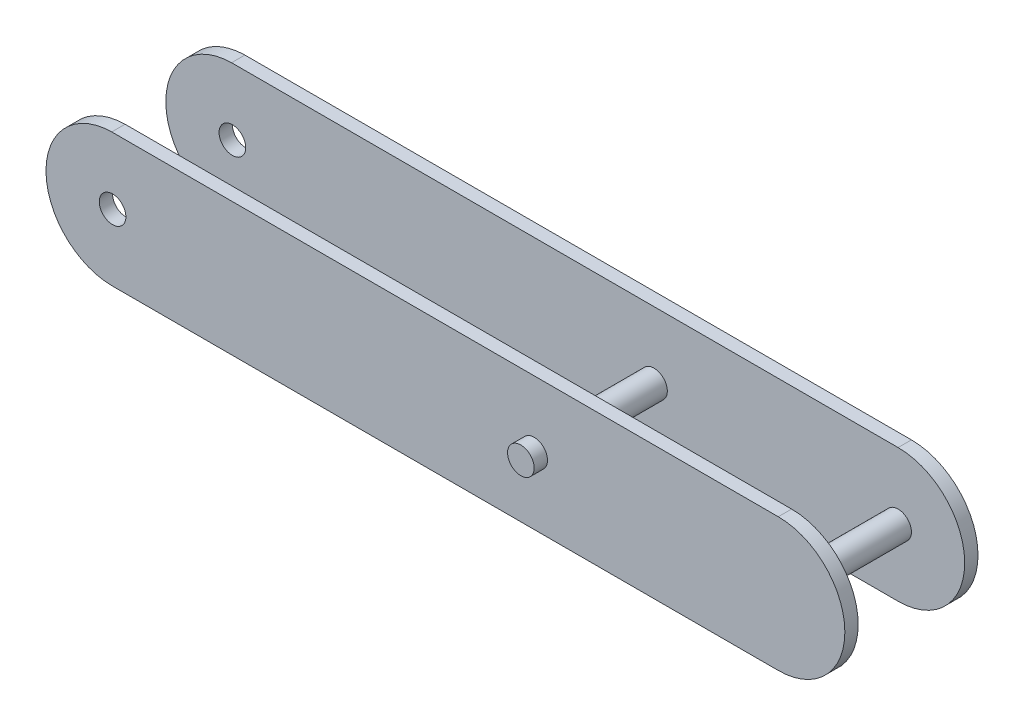
from build123d import *

# Parameters (mm, degrees)
CROQUIS2_R              = 3
SALIENTE_EXTRUIR1_DEPTH = 18
CROQUIS3_R              = 3
SALIENTE_EXTRUIR2_DEPTH = 18
CROQUIS4_W              = 3
CROQUIS4_H              = 30
SALIENTE_EXTRUIR3_DEPTH = 110
CROQUIS5_W              = 3
CROQUIS5_H              = 30
SALIENTE_EXTRUIR4_DEPTH = 70
CORTAR_EXTRUIR1_DEPTH   = 70
CORTAR_EXTRUIR2_DEPTH   = 70
CROQUIS8_R              = 3
CORTAR_EXTRUIR3_DEPTH   = 70
CROQUIS9_R              = 3
SALIENTE_EXTRUIR6_DEPTH = 30


with BuildPart() as part:
    # Croquis2 → Saliente-Extruir1 (new body)
    with BuildSketch(Plane.XY):
        Circle(CROQUIS2_R)
    extrude(amount=SALIENTE_EXTRUIR1_DEPTH)

    # Croquis3 → Saliente-Extruir2 (add)
    with BuildSketch(Plane.XY):
        Circle(CROQUIS3_R)
    extrude(amount=-SALIENTE_EXTRUIR2_DEPTH)

    # Croquis4 → Saliente-Extruir3 (add)
    with BuildSketch(Plane(origin=(0, 0, 0), x_dir=(0, 0, -1), z_dir=(1, 0, 0))):
        with Locations((-13.5, 0)):
            Rectangle(CROQUIS4_W, CROQUIS4_H)
        with Locations((13.5, 0)):
            Rectangle(CROQUIS4_W, CROQUIS4_H)
    extrude(amount=-SALIENTE_EXTRUIR3_DEPTH)

    # Croquis5 → Saliente-Extruir4 (add)
    with BuildSketch(Plane(origin=(0, 0, 0), x_dir=(0, 0, -1), z_dir=(1, 0, 0))):
        with Locations((-13.5, 0)):
            Rectangle(CROQUIS5_W, CROQUIS5_H)
        with Locations((13.5, 0)):
            Rectangle(CROQUIS5_W, CROQUIS5_H)
    extrude(amount=SALIENTE_EXTRUIR4_DEPTH)

    # Croquis6 → Cortar-Extruir1 (cut)
    with BuildSketch(Plane.XY.offset(15)):
        with BuildLine():
            Line((-110, -0.185040896), (-110, -15))
            Line((-110, -15), (-95.185040896, -15))
            ThreePointArc((-95.185040896, -15), (-105.607408735, -10.607408735), (-110, -0.185040896))
        make_face()
        with BuildLine():
            Line((-110, 15), (-110, 0.185040896))
            ThreePointArc((-110, 0.185040896), (-105.607408735, 10.607408735), (-95.185040896, 15))
            Line((-95.185040896, 15), (-110, 15))
        make_face()
    extrude(amount=-CORTAR_EXTRUIR1_DEPTH, mode=Mode.SUBTRACT)

    # Croquis7 → Cortar-Extruir2 (cut)
    with BuildSketch(Plane.XY.offset(15)):
        with BuildLine():
            ThreePointArc((55, 15), (65.606601718, 10.606601718), (70, 0))
            Line((70, 0), (70, 15))
            Line((70, 15), (55, 15))
        make_face()
        with BuildLine():
            ThreePointArc((70, 0), (65.606601718, -10.606601718), (55, -15))
            Line((55, -15), (70, -15))
            Line((70, -15), (70, 0))
        make_face()
    extrude(amount=-CORTAR_EXTRUIR2_DEPTH, mode=Mode.SUBTRACT)

    # Croquis8 → Cortar-Extruir3 (cut)
    with BuildSketch(Plane.XY.offset(15)):
        with Locations((-95, 0)):
            Circle(CROQUIS8_R)
    extrude(amount=-CORTAR_EXTRUIR3_DEPTH, mode=Mode.SUBTRACT)

    # Croquis9 → Saliente-Extruir6 (add)
    with BuildSketch(Plane.XY.offset(15)):
        with Locations((55, 0)):
            Circle(CROQUIS9_R)
    extrude(amount=-SALIENTE_EXTRUIR6_DEPTH)


solid = part.part
